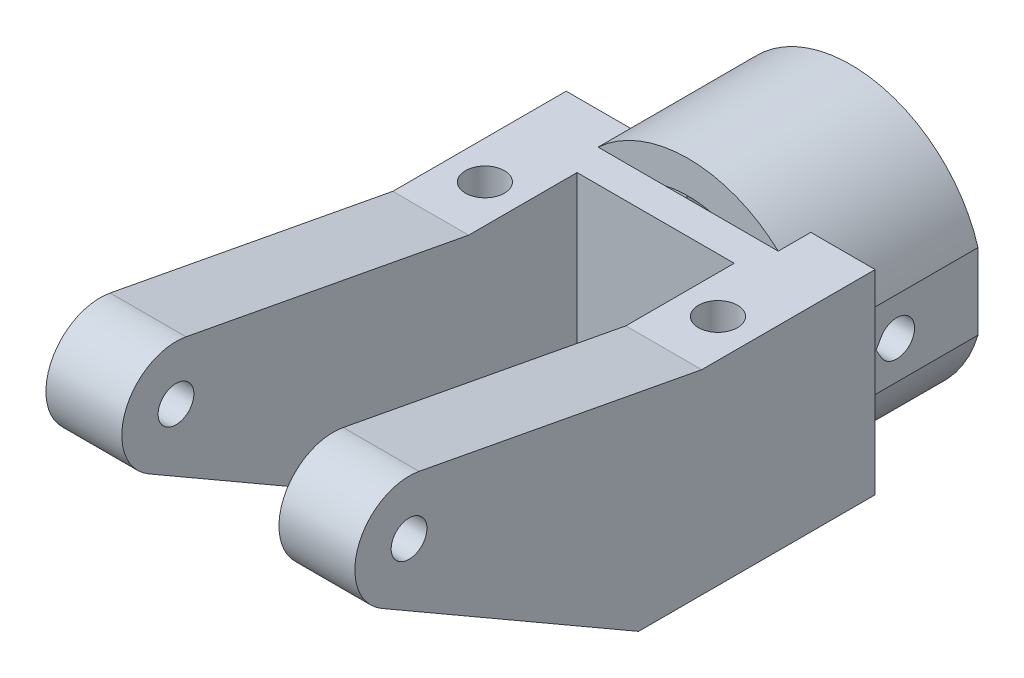
from build123d import *

# Parameters (mm, degrees)
SKETCH_1_R               = 6.325
EXTRUDE_1_DEPTH          = 15
SKETCH_2_W               = 28.5
SKETCH_2_H               = 18
EXTRUDE_2_DEPTH          = 3
EXTRUDE_START            = 14.25
SKETCH_4_R               = 1.65
EXTRUDE_3_DEPTH          = 7
EXTRUDE_START_2          = -14.25
SKETCH_4_2_R             = 1.65
EXTRUDE_4_DEPTH          = 7
EXTRUDE_5_DEPTH          = 7
SKETCH_7_R               = 1.8
CUT_EXTRUDE_1_DEPTH      = 19
CUT_EXTRUDE_3_DEPTH      = 1
CUT_EXTRUDE_3_DEPTH_BACK = 29.5
SKETCH_10_R              = 12.25
SKETCH_10_R_2            = 9.25
EXTRUDE_6_DEPTH          = 15
EXTRUDE_7_DEPTH          = 3
CUT_EXTRUDE_4_DEPTH      = 15.25
CUT_EXTRUDE_4_DEPTH_BACK = 15.25
SKETCH_13_W              = 7.383863518
SKETCH_13_H              = 7
CUT_EXTRUDE_5_DEPTH      = 12
CUT_EXTRUDE_6_DEPTH      = 1.0000001
CUT_EXTRUDE_6_DEPTH_BACK = 61
CHAMFER_3_SIZE           = 1
CHAMFER_3_SIZE2          = 5.67128182


with BuildPart() as part:
    # ｽｹｯﾁ1 → ﾎﾞｽ - 押し出し1 (new body)
    with BuildSketch(Plane.XY):
        Circle(SKETCH_1_R)
    extrude(amount=EXTRUDE_1_DEPTH)

    # ｽｹｯﾁ2 → ﾎﾞｽ - 押し出し2 (add)
    with BuildSketch(Plane.XY.offset(15)):
        Rectangle(SKETCH_2_W, SKETCH_2_H)
    extrude(amount=EXTRUDE_2_DEPTH)

    # ｽｹｯﾁ4 → ﾎﾞｽ - 押し出し3 (add)
    with BuildSketch(Plane(origin=(0, 0, 0), x_dir=(0, 0, -1), z_dir=(1, 0, 0)).offset(EXTRUDE_START)):
        with BuildLine():
            Line((-54.074074074, 13.913518208), (-28, 9))
            Line((-28, 9), (-18, 9))
            Line((-18, 9), (-18, -9))
            Line((-18, -9), (-56.624751337, 4.271344473))
            ThreePointArc((-56.624751337, 4.271344473), (-59.833732287, 10.278683768), (-54.074074074, 13.913518208))
        make_face()
        with Locations((-55, 9)):
            Circle(SKETCH_4_R, mode=Mode.SUBTRACT)
    extrude(amount=-EXTRUDE_3_DEPTH)

    # ｽｹｯﾁ4<2> → ﾎﾞｽ - 押し出し4 (add)
    with BuildSketch(Plane(origin=(0, 0, 0), x_dir=(0, 0, -1), z_dir=(1, 0, 0)).offset(EXTRUDE_START_2)):
        with BuildLine():
            Line((-54.074074074, 13.913518208), (-28, 9))
            Line((-28, 9), (-18, 9))
            Line((-18, 9), (-18, -9))
            Line((-18, -9), (-56.624751337, 4.271344473))
            ThreePointArc((-56.624751337, 4.271344473), (-59.833732287, 10.278683768), (-54.074074074, 13.913518208))
        make_face()
        with Locations((-55, 9)):
            Circle(SKETCH_4_2_R, mode=Mode.SUBTRACT)
    extrude(amount=EXTRUDE_4_DEPTH)

    # ｽｹｯﾁ5 → ﾎﾞｽ - 押し出し5 (add)
    with BuildSketch(Plane.ZY.offset(14.25)):
        with BuildLine():
            Line((18, -9), (33.823085464, -9))
            Line((33.823085464, -9), (57.5, 4.669872981))
            ThreePointArc((57.5, 4.669872981), (57.071979643, 4.44951647), (56.624751337, 4.271344473))
            Line((56.624751337, 4.271344473), (18, -9))
        make_face()
    extrude_5 = extrude(amount=-EXTRUDE_5_DEPTH)

    # ﾐﾗｰ1: ﾎﾞｽ - 押し出し5 across plane
    add(extrude_5.mirror(Plane(origin=(0, 0, 0), x_dir=(0, 0, 1), z_dir=(1, 0, 0))))

    # ｽｹｯﾁ7 → ｶｯﾄ - 押し出し1 (cut, through all)
    with BuildSketch(Plane(origin=(0, 9, 0), x_dir=(1, 0, 0), z_dir=(0, 1, 0))):
        with Locations((10.75, -23)):
            Circle(SKETCH_7_R)
        with Locations((-10.75, -23)):
            Circle(SKETCH_7_R)
    extrude(amount=-CUT_EXTRUDE_1_DEPTH, mode=Mode.SUBTRACT)

    # ｽｹｯﾁ9 → ｶｯﾄ - 押し出し3 (cut, two sides)
    with BuildSketch(Plane(origin=(14.25, 0, 0), x_dir=(0, 0, -1), z_dir=(1, 0, 0))) as cut_extrude_3_sk:
        Polygon((-15, 127.875853754), (-15, 12.993387334), (-15, -12.927364159), (-15, -127.809830579), (214.76493284, -127.809830579), (214.76493284, 127.875853754), align=None)
    extrude(amount=CUT_EXTRUDE_3_DEPTH, mode=Mode.SUBTRACT)
    extrude(cut_extrude_3_sk.sketch, amount=-CUT_EXTRUDE_3_DEPTH_BACK, mode=Mode.SUBTRACT)

    # ｽｹｯﾁ10 → ﾎﾞｽ - 押し出し6 (add)
    with BuildSketch(Plane(origin=(0, 0, 15), x_dir=(-1, 0, 0), z_dir=(0, 0, -1))):
        Circle(SKETCH_10_R)
        Circle(SKETCH_10_R_2, mode=Mode.SUBTRACT)
    extrude(amount=EXTRUDE_6_DEPTH)

    # ｽｹｯﾁ11 → ﾎﾞｽ - 押し出し7 (add)
    with BuildSketch(Plane(origin=(0, 0, 15), x_dir=(-1, 0, 0), z_dir=(0, 0, -1))):
        with BuildLine():
            Line((8.310385069, -9), (14.25, -9))
            Line((14.25, -9), (14.25, 9))
            Line((14.25, 9), (8.310385069, 9))
            ThreePointArc((8.310385069, 9), (12.25, 0), (8.310385069, -9))
        make_face()
        with BuildLine():
            Line((-8.310385069, 9), (-14.25, 9))
            Line((-14.25, 9), (-14.25, -9))
            Line((-14.25, -9), (-8.310385069, -9))
            ThreePointArc((-8.310385069, -9), (-12.25, 0), (-8.310385069, 9))
        make_face()
    extrude(amount=EXTRUDE_7_DEPTH)

    # ｽｹｯﾁ12 → ｶｯﾄ - 押し出し4 (cut, two sides)
    with BuildSketch(Plane(origin=(0, 0, 0), x_dir=(0, 0, -1), z_dir=(1, 0, 0))) as cut_extrude_4_sk:
        with BuildLine():
            Line((-9.405255888, 0), (-8.928941916, 0.825))
            ThreePointArc((-8.928941916, 0.825), (-5.85, 0), (-8.928941916, -0.825))
            Line((-8.928941916, -0.825), (-9.405255888, 0))
        make_face()
    extrude(amount=CUT_EXTRUDE_4_DEPTH, mode=Mode.SUBTRACT)
    extrude(cut_extrude_4_sk.sketch, amount=-CUT_EXTRUDE_4_DEPTH_BACK, mode=Mode.SUBTRACT)

    # ｽｹｯﾁ13 → ｶｯﾄ - 押し出し5 (cut)
    with BuildSketch(Plane(origin=(0, 0, 0), x_dir=(-1, 0, 0), z_dir=(0, 0, -1))):
        with Locations((15.431288641, 0)):
            Rectangle(SKETCH_13_W, SKETCH_13_H)
        with Locations((-15.431288641, 0)):
            Rectangle(SKETCH_13_W, SKETCH_13_H)
    extrude(amount=-CUT_EXTRUDE_5_DEPTH, mode=Mode.SUBTRACT)

    # ｽｹｯﾁ14 → ｶｯﾄ - 押し出し6 (cut, two sides)
    with BuildSketch(Plane(origin=(0, 0, 0), x_dir=(-1, 0, 0), z_dir=(0, 0, -1))) as cut_extrude_6_sk:
        Polygon((76.843424889, -11.578536177), (4, -11.578536177), (-4, -11.578536177), (-76.843424889, -11.578536177), (-76.843424889, -157.265385955), (76.843424889, -157.265385955), align=None)
    extrude(amount=CUT_EXTRUDE_6_DEPTH, mode=Mode.SUBTRACT)
    extrude(cut_extrude_6_sk.sketch, amount=-CUT_EXTRUDE_6_DEPTH_BACK, mode=Mode.SUBTRACT)

    # 面取り3
    chamfer_3_edges = [part.edges().sort_by_distance(p)[0] for p in [
        (0, -11.578536177, 0),
    ]]
    chamfer_3_side = [part.faces().sort_by_distance(p)[0] for p in [
        (-11.404834964, 0, 0),
    ]]
    chamfer(chamfer_3_edges, length=CHAMFER_3_SIZE, length2=CHAMFER_3_SIZE2, reference=chamfer_3_side[0])


solid = part.part
